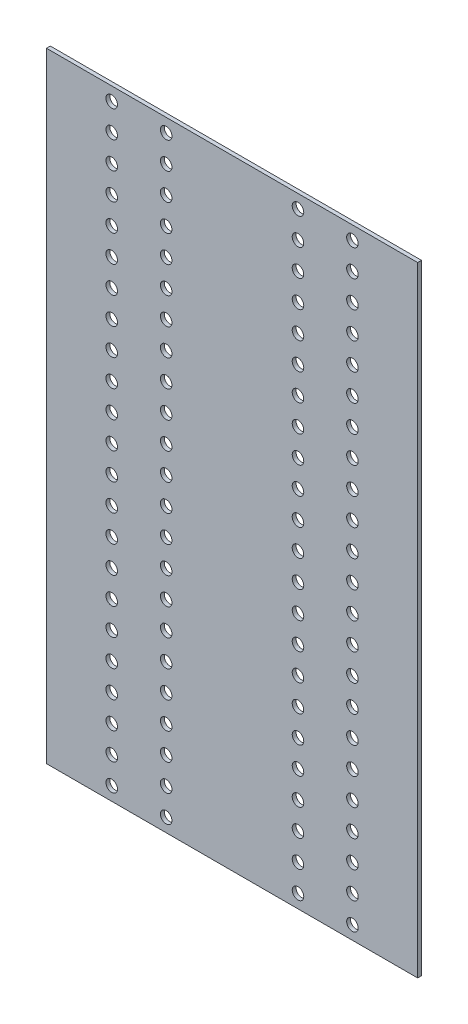
from build123d import *

# Parameters (mm, degrees)
SKETCH1_W            = 289.4
SKETCH1_H            = 483
BOSS_EXTRUDE1_DEPTH  = 3
M8_CLEARANCE_HOLE1_D = 9


with BuildPart() as part:
    # Sketch1 → Boss-Extrude1 (new body)
    with BuildSketch(Plane.XY):
        with Locations((144.7, 241.5)):
            Rectangle(SKETCH1_W, SKETCH1_H)
    extrude(amount=BOSS_EXTRUDE1_DEPTH)

    # M8 Clearance Hole1 (through all)
    with Locations(Plane.XY.offset(3)):
        with Locations((238.52, 10.5), (196.08, 10.5), (93.32, 10.5), (50.88, 10.5), (238.52, 31.5), (196.08, 31.5), (93.32, 31.5), (50.88, 31.5), (238.52, 52.5), (196.08, 52.5), (93.32, 52.5), (50.88, 52.5), (238.52, 73.5), (196.08, 73.5), (93.32, 73.5), (50.88, 73.5), (238.52, 94.5), (196.08, 94.5), (93.32, 94.5), (50.88, 94.5), (238.52, 115.5), (196.08, 115.5), (93.32, 115.5), (50.88, 115.5), (238.52, 136.5), (196.08, 136.5), (93.32, 136.5), (50.88, 136.5), (238.52, 157.5), (196.08, 157.5), (93.32, 157.5), (50.88, 157.5), (238.52, 178.5), (196.08, 178.5), (93.32, 178.5), (50.88, 178.5), (238.52, 199.5), (196.08, 199.5), (93.32, 199.5), (50.88, 199.5), (238.52, 220.5), (196.08, 220.5), (93.32, 220.5), (50.88, 220.5), (238.52, 241.5), (196.08, 241.5), (93.32, 241.5), (50.88, 241.5), (238.52, 262.5), (196.08, 262.5), (93.32, 262.5), (50.88, 262.5), (238.52, 283.5), (196.08, 283.5), (93.32, 283.5), (50.88, 283.5), (238.52, 304.5), (196.08, 304.5), (93.32, 304.5), (50.88, 304.5), (238.52, 325.5), (196.08, 325.5), (93.32, 325.5), (50.88, 325.5), (238.52, 346.5), (196.08, 346.5), (93.32, 346.5), (50.88, 346.5), (238.52, 367.5), (196.08, 367.5), (93.32, 367.5), (50.88, 367.5), (238.52, 388.5), (196.08, 388.5), (93.32, 388.5), (50.88, 388.5), (238.52, 409.5), (196.08, 409.5), (93.32, 409.5), (50.88, 409.5), (238.52, 430.5), (196.08, 430.5), (93.32, 430.5), (50.88, 430.5), (238.52, 451.5), (196.08, 451.5), (93.32, 451.5), (50.88, 451.5), (238.52, 472.5), (196.08, 472.5), (93.32, 472.5), (50.88, 472.5)):
            Hole(M8_CLEARANCE_HOLE1_D / 2)


solid = part.part
